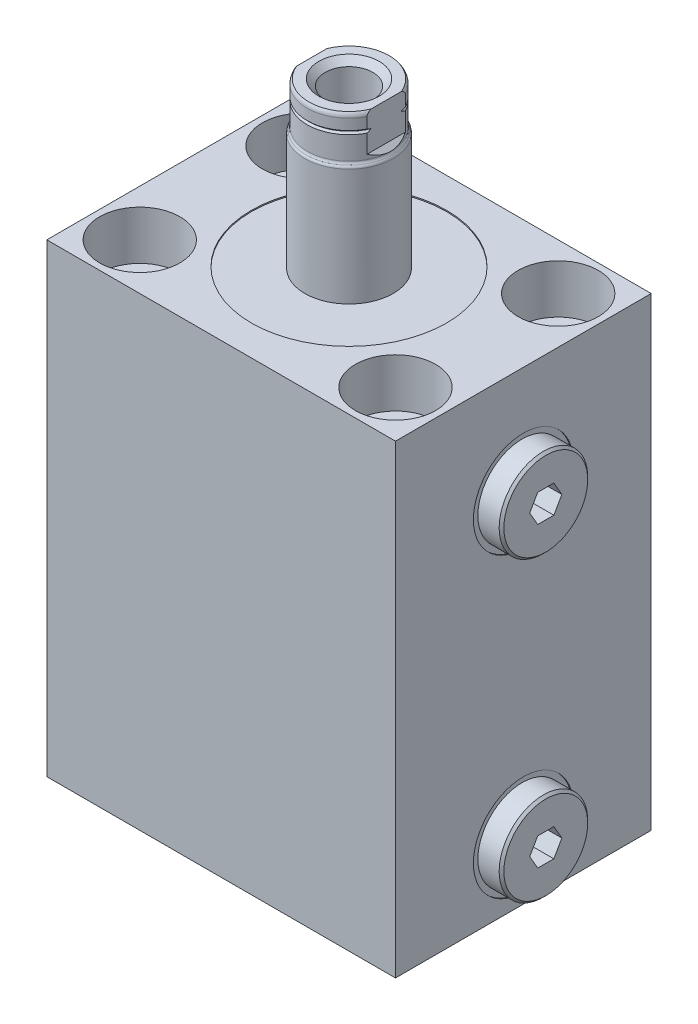
from build123d import *

# Parameters (mm, degrees)
SKETCH1_W                  = 75
SKETCH1_H                  = 55
EXTRUDE1_DEPTH             = 100
SKETCH2_R                  = 21
CUT_EXTRUDE1_DEPTH         = 0.254
CHAMFER1_SIZE              = 0.508
CUT_EXTRUDE2_DEPTH         = 5.9944
LPATTERN1_COUNT            = 2
LPATTERN1_PITCH            = 64
CHAMFER1_OF_LPATTERN1_SIZE = 0.508
SKETCH7_R                  = 0.889
LPATTERN2_COUNT            = 2
LPATTERN2_PITCH            = 27.5
CUT_EXTRUDE3_DEPTH         = 28.5
CUT_EXTRUDE3_DEPTH_BACK    = 28.5
HOLE1_D                    = 10.49
HOLE1_CBORE_D              = 17.247
HOLE1_CBORE_DEPTH          = 10.49


with BuildPart() as part:
    # Sketch1 → Extrude1 (new body)
    with BuildSketch(Plane(origin=(0, 0, 0), x_dir=(1, 0, 0), z_dir=(0, 1, 0))):
        Rectangle(SKETCH1_W, SKETCH1_H)
    extrude(amount=EXTRUDE1_DEPTH)

    # Sketch2 → Cut-Extrude1 (cut)
    with BuildSketch(Plane(origin=(0, 100, 0), x_dir=(1, 0, 0), z_dir=(0, 1, 0))):
        with Locations(Location((0, 0, 0), (0, 0, 270))):  # turned: the seam where the file's is
            Circle(SKETCH2_R)
    extrude(amount=-CUT_EXTRUDE1_DEPTH, mode=Mode.SUBTRACT)

    # Sketch3 → Cut-Revolve1 (revolve, cut)
    with BuildSketch(Plane.XY, mode=Mode.PRIVATE) as cut_revolve1_sk:
        Polygon((37.5, 77), (37.5, 66.256), (37.246, 66.256), (37.246, 70.3452), (36.5348, 71.0564), (21.752, 71.0564), (21.752, 77), align=None)
    cut_revolve1 = revolve(cut_revolve1_sk.sketch.rotate(Axis((-6.847979502, 77, 0), (1, 0, 0)), 270), axis=Axis((-6.847979502, 77, 0), (1, 0, 0)), mode=Mode.SUBTRACT)  # turned: the seam where the file's is

    # Sketch4 → Revolve1 (revolve)
    with BuildSketch(Plane.XY, mode=Mode.PRIVATE) as revolve1_sk:
        Polygon((25.308, 77), (25.308, 82.9182), (37.246, 82.9182), (37.246, 86.525), (42.326, 86.525), (42.326, 77), align=None)
    revolve1 = revolve(revolve1_sk.sketch.rotate(Axis((8.732572807, 77, 0), (1, 0, 0)), 90), axis=Axis((8.732572807, 77, 0), (1, 0, 0)))  # turned: the seam where the file's is

    # Chamfer1
    chamfer1_edges = [part.edges().sort_by_distance(p)[0] for p in [
        (42.326, 77, -9.525),
    ]]
    chamfer(chamfer1_edges, length=CHAMFER1_SIZE)

    # Sketch5 → Cut-Extrude2 (cut)
    with BuildSketch(Plane(origin=(42.326, 0, 0), x_dir=(0, 0, -1), z_dir=(1, 0, 0))):
        Polygon((1.730434227, 79.9972), (-1.730434227, 79.9972), (-3.460868454, 77), (-1.730434227, 74.0028), (1.730434227, 74.0028), (3.460868454, 77), align=None)
    cut_extrude2 = extrude(amount=-CUT_EXTRUDE2_DEPTH, mode=Mode.SUBTRACT)

    # LPattern1: Cut-Revolve1, Revolve1, Cut-Extrude2 ×2
    with Locations(*[(0, -i * LPATTERN1_PITCH, 0) for i in range(1, LPATTERN1_COUNT)]):
        add(cut_revolve1, mode=Mode.SUBTRACT)
        add(revolve1)
        add(cut_extrude2, mode=Mode.SUBTRACT)

    # Chamfer1 of LPattern1
    chamfer1_of_lpattern1_edges = [part.edges().sort_by_distance(p)[0] for p in [
        (42.326, 13, -9.525),
    ]]
    chamfer(chamfer1_of_lpattern1_edges, length=CHAMFER1_OF_LPATTERN1_SIZE)

    # Sketch6 → Cut-Revolve2 (revolve, cut)
    with BuildSketch(Plane.XY, mode=Mode.PRIVATE) as cut_revolve2_sk:
        Polygon((0, 0), (0, 14.895831126), (1.2446, 14.148), (1.2446, 4.9529), (1.7525, 4.445), (3.2512, 4.445), (3.2512, 1.448), (5.7025, 1.448), (5.7025, 0), align=None)
    cut_revolve2 = revolve(cut_revolve2_sk.sketch.rotate(Axis((0, 0, 0), (0, 1, 0)), 90), axis=Axis((0, 0, 0), (0, 1, 0)), mode=Mode.SUBTRACT)  # turned: the seam where the file's is

    # Sketch7 → Revolve3 (revolve)
    with BuildSketch(Plane.XY, mode=Mode.PRIVATE) as revolve3_sk:
        with Locations((4.814, 0.5844)):
            Circle(SKETCH7_R)
    revolve3 = revolve(revolve3_sk.sketch.rotate(Axis((0, 0, 0), (0, 1, 0)), 90), axis=Axis((0, 0, 0), (0, 1, 0)))  # turned: the seam where the file's is

    # LPattern2: Cut-Revolve2, Revolve3 ×2
    with Locations(*[(-i * LPATTERN2_PITCH, 0, 0) for i in range(1, LPATTERN2_COUNT)]):
        add(cut_revolve2, mode=Mode.SUBTRACT)
        add(revolve3)

    # Sketch8 → Revolve4 (revolve)
    with BuildSketch(Plane.XY, mode=Mode.PRIVATE) as revolve4_sk:
        with BuildLine():
            Line((9.5, 99.746), (9.5, 124.871283915))
            ThreePointArc((9.5, 124.871283915), (9.434702232, 125.179909902), (9.25, 125.435641958))
            ThreePointArc((9.25, 125.435641958), (9.065297768, 125.691374013), (9, 126))
            Line((9, 126), (9, 134.0094))
            ThreePointArc((9, 134.0094), (8.905612002, 134.537401443), (8.634139733, 135))
            Line((8.634139733, 135), (0, 135))
            Line((0, 135), (0, 99.746))
            Line((0, 99.746), (9.5, 99.746))
        make_face()
    revolve(revolve4_sk.sketch.rotate(Axis((0, 0, 0), (0, 1, 0)), 90), axis=Axis((0, 0, 0), (0, 1, 0)))  # turned: the seam where the file's is

    # Sketch10 → Cut-Revolve3 (revolve, cut)
    with BuildSketch(Plane.XY, mode=Mode.PRIVATE) as cut_revolve3_sk:
        Polygon((6.5, 135), (5.131, 133.631), (5.131, 114.68), (0, 111.596984164), (0, 135), align=None)
    revolve(cut_revolve3_sk.sketch.rotate(Axis((0, 135, 0), (0, -1, 0)), 270), axis=Axis((0, 135, 0), (0, -1, 0)), mode=Mode.SUBTRACT)  # turned: the seam where the file's is

    # Sketch11 → Cut-Revolve4 (revolve, cut)
    with BuildSketch(Plane.XY, mode=Mode.PRIVATE) as cut_revolve4_sk:
        Polygon((9, 131.698), (8.619, 131.317), (9, 130.936), align=None)
    revolve(cut_revolve4_sk.sketch.rotate(Axis((0, 0, 0), (0, 1, 0)), 90), axis=Axis((0, 0, 0), (0, 1, 0)), mode=Mode.SUBTRACT)  # turned: the seam where the file's is

    # Sketch12 → Cut-Extrude3 (cut, two sides)
    with BuildSketch(Plane.XY) as cut_extrude3_sk:
        Polygon((8, 135), (8, 127), (9.5, 125.5), (9.5, 135), align=None)
        Polygon((-9.5, 135), (-8, 135), (-8, 127), (-9.5, 125.5), align=None)
    extrude(amount=CUT_EXTRUDE3_DEPTH, mode=Mode.SUBTRACT)
    extrude(cut_extrude3_sk.sketch, amount=-CUT_EXTRUDE3_DEPTH_BACK, mode=Mode.SUBTRACT)

    # Hole1 (through all)
    with Locations(Plane(origin=(0, 100, 0), x_dir=(-1, 0, 0), z_dir=(0, 1, 0))):
        with Locations((27.5, 17.5), (27.5, -17.5), (-27.5, -17.5), (-27.5, 17.5)):
            CounterBoreHole(HOLE1_D / 2, HOLE1_CBORE_D / 2, HOLE1_CBORE_DEPTH)


solid = part.part
